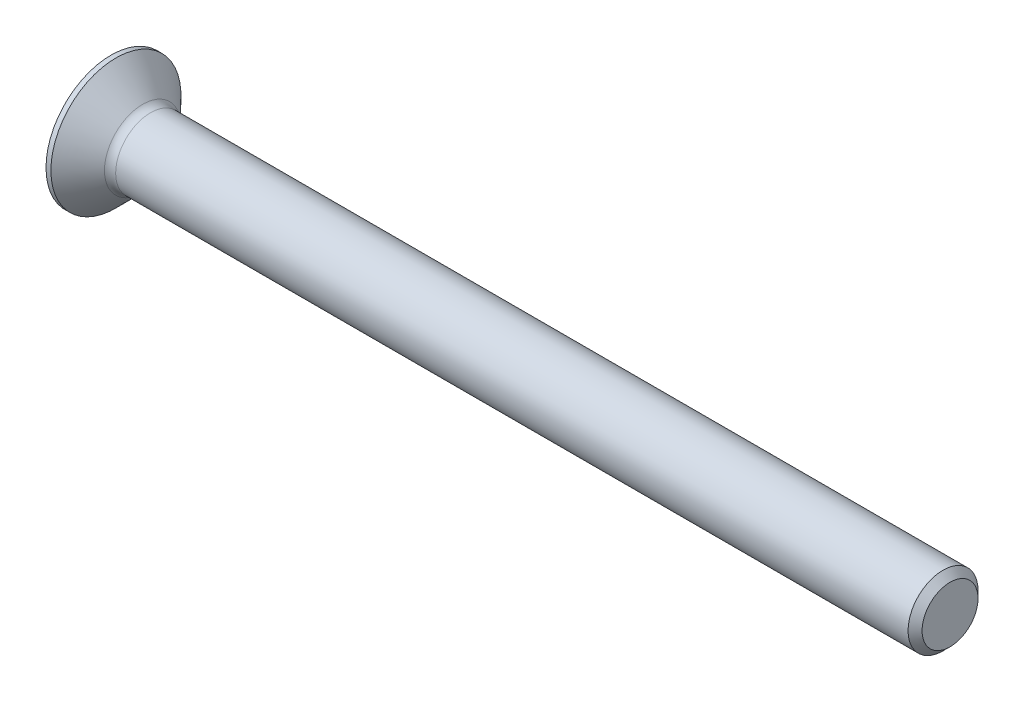
from build123d import *

# Parameters (mm, degrees)
FILLET1_R       = 0.8
SKETCH3_W       = 1
SKETCH3_H       = 5
SKETCH4_W       = 0.74
SKETCH4_H       = 1
RECPAT_COUNT    = 2
RECPAT_ANGLE    = 90
CHANFREIN1_SIZE = 0.5


with BuildPart() as part:
    # BodySke → Base-Revolve (revolve)
    with BuildSketch(Plane.XY, mode=Mode.PRIVATE) as base_revolve_sk:
        Polygon((0, 0), (0, 4.65), (0.35, 4.65), (2.5, 2.5), (60, 2.5), (60, 0), align=None)
    revolve(base_revolve_sk.sketch.rotate(Axis((-6.35, 0, 0), (1, 0, 0)), 90), axis=Axis((-6.35, 0, 0), (1, 0, 0)))  # turned: the seam where the file's is

    # Fillet1
    fillet1_edges = [part.edges().sort_by_distance(p)[0] for p in [
        (2.5, 0, -2.5),
    ]]
    fillet(fillet1_edges, radius=FILLET1_R)

    # Sketch3 → Recess section 0
    with BuildSketch(Plane.ZY):
        Rectangle(SKETCH3_W, SKETCH3_H)
    # Sketch4 → Recess section 1
    with BuildSketch(Plane.ZY.offset(-2.01)):
        with Locations((-0.13, 0)):
            Rectangle(SKETCH4_W, SKETCH4_H)
    recess = loft(mode=Mode.SUBTRACT)

    # RecPat: Recess ×2 about axis
    recpat_axis = Axis((0, 0, 0), (1, 0, 0))
    for i in range(1, RECPAT_COUNT):
        add(recess.rotate(recpat_axis, i * RECPAT_ANGLE / (RECPAT_COUNT - 1)), mode=Mode.SUBTRACT)

    # RecCorSke → RecessCore (revolve, cut)
    with BuildSketch(Plane.XY, mode=Mode.PRIVATE) as recesscore_sk:
        Polygon((0, 0), (0, 0.696552892), (2.01, 0.556), (2.190655351, 0), align=None)
    revolve(recesscore_sk.sketch.rotate(Axis((-3.175, 0, 0), (1, 0, 0)), 90), axis=Axis((-3.175, 0, 0), (1, 0, 0)), mode=Mode.SUBTRACT)  # turned: the seam where the file's is

    # Chanfrein1
    chanfrein1_edges = [part.edges().sort_by_distance(p)[0] for p in [
        (60, 0, -2.5),
    ]]
    chamfer(chanfrein1_edges, length=CHANFREIN1_SIZE)


solid = part.part
